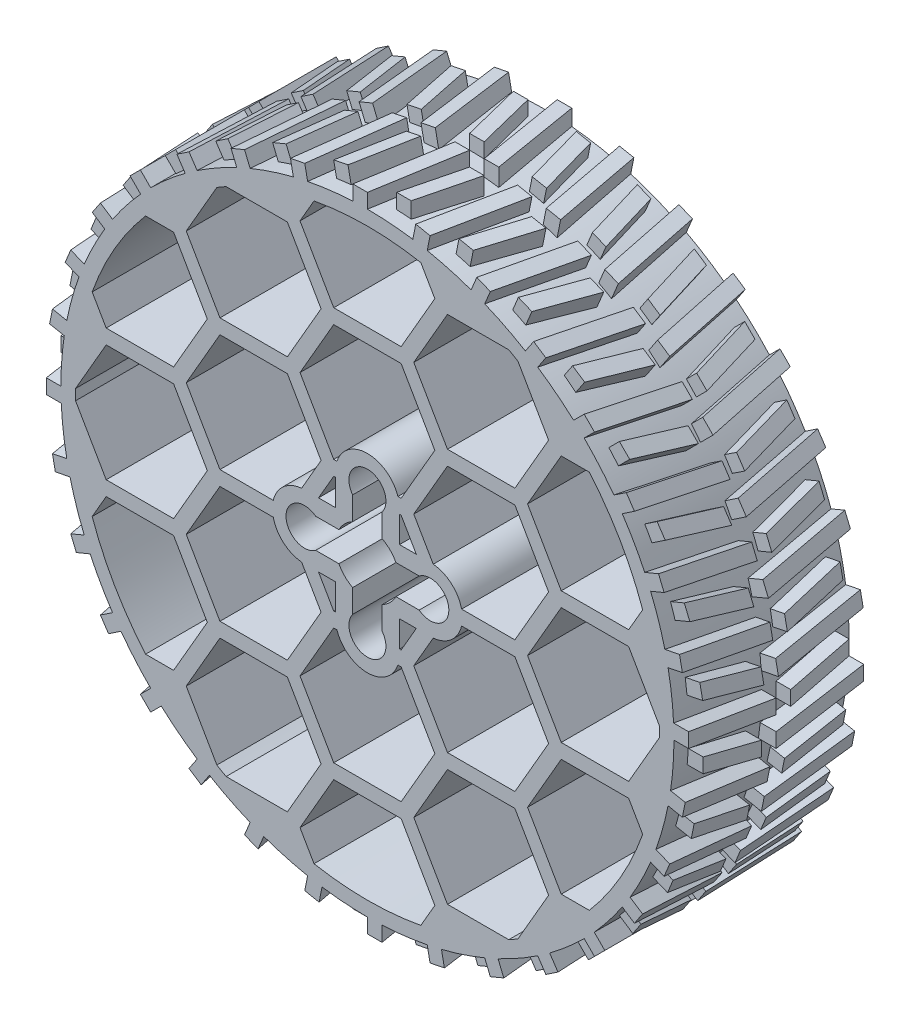
from build123d import *

# Parameters (mm, degrees)
SKETCH1_R           = 105
BOSS_EXTRUDE1_DEPTH = 60
SKETCH1_4_R         = 6.338999997
SKETCH1_4_R_2       = 3.175000013
SKETCH1_4_R_3       = 6.339
SKETCH1_4_R_4       = 3.175000003
SKETCH1_4_R_5       = 6.338999989
SKETCH1_4_R_6       = 3.175000016
BOSS_EXTRUDE2_DEPTH = 10
SKETCH1_6_R         = 6.339
SKETCH1_6_R_2       = 3.175000016
SKETCH1_6_R_3       = 6.338999989
SKETCH1_6_R_4       = 3.175000013
SKETCH1_6_R_5       = 3.175000003
SKETCH1_6_R_6       = 6.338999997
BOSS_EXTRUDE4_DEPTH = 30
BOSS_EXTRUDE5_START = -2
BOSS_EXTRUDE5_DEPTH = 7
CIRPATTERN1_COUNT   = 32


with BuildPart() as part:
    # Sketch1 → Boss-Extrude1 (new body)
    with BuildSketch(Plane.XY):
        Circle(SKETCH1_R)
        with BuildLine():
            Line((-11.547005384, 70), (-23.094010768, 90))
            Line((-23.094010768, 90), (-18.294940862, 98.312232905))
            ThreePointArc((-18.294940862, 98.312232905), (0, 100), (18.294940862, 98.312232905))
            Line((18.294940862, 98.312232905), (23.094010768, 90))
            Line((23.094010768, 90), (11.547005384, 70))
            Line((11.547005384, 70), (-11.547005384, 70))
        make_face(mode=Mode.SUBTRACT)
        with BuildLine():
            Line((-48.412291828, 87.5), (-27.424137787, 87.5))
            Line((-27.424137787, 87.5), (-15.877132403, 67.5))
            Line((-15.877132403, 67.5), (-27.424137787, 47.5))
            Line((-27.424137787, 47.5), (-50.518148554, 47.5))
            Line((-50.518148554, 47.5), (-62.065153938, 67.5))
            Line((-62.065153938, 67.5), (-51.571076917, 85.676274578))
            ThreePointArc((-51.571076917, 85.676274578), (-50, 86.602540378), (-48.412291828, 87.5))
        make_face(mode=Mode.SUBTRACT)
        with BuildLine():
            Line((27.424137787, 87.5), (48.412291828, 87.5))
            ThreePointArc((48.412291828, 87.5), (50, 86.602540378), (51.571076917, 85.676274578))
            Line((51.571076917, 85.676274578), (62.065153938, 67.5))
            Line((62.065153938, 67.5), (50.518148554, 47.5))
            Line((50.518148554, 47.5), (27.424137787, 47.5))
            Line((27.424137787, 47.5), (15.877132403, 67.5))
            Line((15.877132403, 67.5), (27.424137787, 87.5))
        make_face(mode=Mode.SUBTRACT)
        with BuildLine():
            Line((-75.993420768, 65), (-66.395280957, 65))
            Line((-66.395280957, 65), (-54.848275573, 45))
            Line((-54.848275573, 45), (-66.395280957, 25))
            Line((-66.395280957, 25), (-89.489291724, 25))
            Line((-89.489291724, 25), (-94.28836163, 33.312232905))
            ThreePointArc((-94.28836163, 33.312232905), (-86.602540378, 50), (-75.993420768, 65))
        make_face(mode=Mode.SUBTRACT)
        with BuildLine():
            Line((66.395280957, 65), (75.993420768, 65))
            ThreePointArc((75.993420768, 65), (86.602540378, 50), (94.28836163, 33.312232905))
            Line((94.28836163, 33.312232905), (89.489291724, 25))
            Line((89.489291724, 25), (66.395280957, 25))
            Line((66.395280957, 25), (54.848275573, 45))
            Line((54.848275573, 45), (66.395280957, 65))
        make_face(mode=Mode.SUBTRACT)
        with BuildLine():
            Line((-99.983368745, 1.823725422), (-89.489291724, 20))
            Line((-89.489291724, 20), (-66.395280957, 20))
            Line((-66.395280957, 20), (-54.848275573, 0))
            Line((-54.848275573, 0), (-66.395280957, -20))
            Line((-66.395280957, -20), (-89.489291724, -20))
            Line((-89.489291724, -20), (-99.983368745, -1.823725422))
            ThreePointArc((-99.983368745, -1.823725422), (-100, 0), (-99.983368745, 1.823725422))
        make_face(mode=Mode.SUBTRACT)
        with BuildLine():
            Line((89.489291724, 20), (99.983368745, 1.823725422))
            ThreePointArc((99.983368745, 1.823725422), (100, 0), (99.983368745, -1.823725422))
            Line((99.983368745, -1.823725422), (89.489291724, -20))
            Line((89.489291724, -20), (66.395280957, -20))
            Line((66.395280957, -20), (54.848275573, 0))
            Line((54.848275573, 0), (66.395280957, 20))
            Line((66.395280957, 20), (89.489291724, 20))
        make_face(mode=Mode.SUBTRACT)
        with BuildLine():
            Line((-94.28836163, -33.312232905), (-89.489291724, -25))
            Line((-89.489291724, -25), (-66.395280957, -25))
            Line((-66.395280957, -25), (-54.848275573, -45))
            Line((-54.848275573, -45), (-66.395280957, -65))
            Line((-66.395280957, -65), (-75.993420768, -65))
            ThreePointArc((-75.993420768, -65), (-86.602540378, -50), (-94.28836163, -33.312232905))
        make_face(mode=Mode.SUBTRACT)
        with BuildLine():
            Line((89.489291724, -25), (94.28836163, -33.312232905))
            ThreePointArc((94.28836163, -33.312232905), (86.602540378, -50), (75.993420768, -65))
            Line((75.993420768, -65), (66.395280957, -65))
            Line((66.395280957, -65), (54.848275573, -45))
            Line((54.848275573, -45), (66.395280957, -25))
            Line((66.395280957, -25), (89.489291724, -25))
        make_face(mode=Mode.SUBTRACT)
        with BuildLine():
            Line((-51.571076917, -85.676274578), (-62.065153938, -67.5))
            Line((-62.065153938, -67.5), (-50.518148554, -47.5))
            Line((-50.518148554, -47.5), (-27.424137787, -47.5))
            Line((-27.424137787, -47.5), (-15.877132403, -67.5))
            Line((-15.877132403, -67.5), (-27.424137787, -87.5))
            Line((-27.424137787, -87.5), (-48.412291828, -87.5))
            ThreePointArc((-48.412291828, -87.5), (-50, -86.602540378), (-51.571076917, -85.676274578))
        make_face(mode=Mode.SUBTRACT)
        with BuildLine():
            Line((62.065153938, -67.5), (51.571076917, -85.676274578))
            ThreePointArc((51.571076917, -85.676274578), (50, -86.602540378), (48.412291828, -87.5))
            Line((48.412291828, -87.5), (27.424137787, -87.5))
            Line((27.424137787, -87.5), (15.877132403, -67.5))
            Line((15.877132403, -67.5), (27.424137787, -47.5))
            Line((27.424137787, -47.5), (50.518148554, -47.5))
            Line((50.518148554, -47.5), (62.065153938, -67.5))
        make_face(mode=Mode.SUBTRACT)
        with BuildLine():
            Line((-18.294940862, -98.312232905), (-23.094010768, -90))
            Line((-23.094010768, -90), (-11.547005384, -70))
            Line((-11.547005384, -70), (11.547005384, -70))
            Line((11.547005384, -70), (23.094010768, -90))
            Line((23.094010768, -90), (18.294940862, -98.312232905))
            ThreePointArc((18.294940862, -98.312232905), (0, -100), (-18.294940862, -98.312232905))
        make_face(mode=Mode.SUBTRACT)
        with BuildLine():
            ThreePointArc((-32.260142561, -2.5), (-28.768380758, -8.298560137), (-22.542678431, -10.954935619))
            Line((-22.542678431, -10.954935619), (-15.877132403, -22.5))
            Line((-15.877132403, -22.5), (-27.424137787, -42.5))
            Line((-27.424137787, -42.5), (-50.518148554, -42.5))
            Line((-50.518148554, -42.5), (-62.065153938, -22.5))
            Line((-62.065153938, -22.5), (-50.518148554, -2.5))
            Line((-50.518148554, -2.5), (-32.260142561, -2.5))
        make_face(mode=Mode.SUBTRACT)
        Polygon((-16.743157813, -10.999999989), (-10.999999973, -10.999999989), (-10.999999973, -20), (-11.547005384, -20), align=None, mode=Mode.SUBTRACT)
        with BuildLine():
            ThreePointArc((-10.444314008, -25), (3.3e-08, -32.547999956), (10.444314074, -25))
            Line((10.444314074, -25), (11.547005384, -25))
            Line((11.547005384, -25), (23.094010768, -45))
            Line((23.094010768, -45), (11.547005384, -65))
            Line((11.547005384, -65), (-11.547005384, -65))
            Line((-11.547005384, -65), (-23.094010768, -45))
            Line((-23.094010768, -45), (-11.547005384, -25))
            Line((-11.547005384, -25), (-10.444314008, -25))
        make_face(mode=Mode.SUBTRACT)
        Polygon((11.00000004, -11.000000006), (16.743157803, -11.000000006), (11.547005384, -20), (11.00000004, -20), align=None, mode=Mode.SUBTRACT)
        with BuildLine():
            ThreePointArc((22.542678416, -10.954935645), (28.768380811, -8.298560182), (32.260142649, -2.5))
            Line((32.260142649, -2.5), (50.518148554, -2.5))
            Line((50.518148554, -2.5), (62.065153938, -22.5))
            Line((62.065153938, -22.5), (50.518148554, -42.5))
            Line((50.518148554, -42.5), (27.424137787, -42.5))
            Line((27.424137787, -42.5), (15.877132403, -22.5))
            Line((15.877132403, -22.5), (22.542678416, -10.954935645))
        make_face(mode=Mode.SUBTRACT)
        with BuildLine():
            ThreePointArc((-22.54267841, 10.954935656), (-28.768380763, 8.298560168), (-32.26014257, 2.5))
            Line((-32.26014257, 2.5), (-50.518148554, 2.5))
            Line((-50.518148554, 2.5), (-62.065153938, 22.5))
            Line((-62.065153938, 22.5), (-50.518148554, 42.5))
            Line((-50.518148554, 42.5), (-27.424137787, 42.5))
            Line((-27.424137787, 42.5), (-15.877132403, 22.5))
            Line((-15.877132403, 22.5), (-22.54267841, 10.954935656))
        make_face(mode=Mode.SUBTRACT)
        Polygon((-10.999999956, 20), (-10.999999956, 11.000000024), (-16.743157793, 11.000000024), (-11.547005384, 20), align=None, mode=Mode.SUBTRACT)
        with BuildLine():
            ThreePointArc((10.444314098, 25), (5.1e-08, 32.547999973), (-10.444313996, 25))
            Line((-10.444313996, 25), (-11.547005384, 25))
            Line((-11.547005384, 25), (-23.094010768, 45))
            Line((-23.094010768, 45), (-11.547005384, 65))
            Line((-11.547005384, 65), (11.547005384, 65))
            Line((11.547005384, 65), (23.094010768, 45))
            Line((23.094010768, 45), (11.547005384, 25))
            Line((11.547005384, 25), (10.444314098, 25))
        make_face(mode=Mode.SUBTRACT)
        with BuildLine():
            Line((9.767988869, 5.058299477), (17.727459807, 5.058299477))
            ThreePointArc((17.72745981, 5.058299474), (27.886999964, -4.5e-08), (17.727459795, -5.058299534))
            Line((17.727459789, -5.058299543), (9.767988835, -5.058299543))
            ThreePointArc((9.767988835, -5.058299543), (7.778174571, -7.778174624), (5.058299477, -9.767988869))
            Line((5.058299477, -9.767988869), (5.058299477, -17.727459807))
            ThreePointArc((5.058299479, -17.727459806), (-5e-08, -27.886999949), (-5.058299543, -17.727459788))
            Line((-5.058299543, -17.727459789), (-5.058299543, -9.767988835))
            ThreePointArc((-5.058299543, -9.767988835), (-7.778174624, -7.778174571), (-9.767988869, -5.058299477))
            Line((-9.767988869, -5.058299477), (-17.727459807, -5.058299477))
            ThreePointArc((-17.72745982, -5.05829946), (-27.886999941, 7.3e-08), (-17.727459789, 5.058299543))
            Line((-17.727459789, 5.058299543), (-9.767988835, 5.058299543))
            ThreePointArc((-9.767988835, 5.058299543), (-7.778174571, 7.778174624), (-5.058299477, 9.767988869))
            Line((-5.058299477, 9.767988869), (-5.058299477, 17.727459807))
            ThreePointArc((-5.058299461, 17.72745982), (6.9e-08, 27.886999964), (5.05829954, 17.727459791))
            Line((5.058299543, 17.727459789), (5.058299543, 9.767988835))
            ThreePointArc((5.058299543, 9.767988835), (7.778174624, 7.778174571), (9.767988869, 5.058299477))
        make_face(mode=Mode.SUBTRACT)
        Polygon((11.000000057, 11.000000006), (11.000000057, 20), (11.547005384, 20), (16.743157803, 11.000000006), align=None, mode=Mode.SUBTRACT)
        with BuildLine():
            ThreePointArc((32.260142649, 2.5), (28.768380811, 8.298560182), (22.542678416, 10.954935645))
            Line((22.542678416, 10.954935645), (15.877132403, 22.5))
            Line((15.877132403, 22.5), (27.424137787, 42.5))
            Line((27.424137787, 42.5), (50.518148554, 42.5))
            Line((50.518148554, 42.5), (62.065153938, 22.5))
            Line((62.065153938, 22.5), (50.518148554, 2.5))
            Line((50.518148554, 2.5), (32.260142649, 2.5))
        make_face(mode=Mode.SUBTRACT)
    extrude(amount=BOSS_EXTRUDE1_DEPTH)

    # Sketch1_4 → Boss-Extrude2 (add)
    with BuildSketch(Plane.XY):
        with Locations((5.1e-08, 21.547999967)):
            Circle(SKETCH1_4_R)
        with Locations((5.1e-08, 21.547999967)):
            Circle(SKETCH1_4_R_2, mode=Mode.SUBTRACT)
        with Locations((21.547999964, -3.6e-08)):
            Circle(SKETCH1_4_R_3)
        with Locations((21.547999974, -2.6e-08)):
            Circle(SKETCH1_4_R_4, mode=Mode.SUBTRACT)
        with Locations((-21.547999952, 5.4e-08)):
            Circle(SKETCH1_4_R_5)
        with Locations((-21.547999942, 4.4e-08)):
            Circle(SKETCH1_4_R_2, mode=Mode.SUBTRACT)
        with Locations((-3.9e-08, -21.547999949)):
            Circle(SKETCH1_4_R_3)
        with Locations((-1.9e-08, -21.547999949)):
            Circle(SKETCH1_4_R_6, mode=Mode.SUBTRACT)
    extrude(amount=BOSS_EXTRUDE2_DEPTH)

    # Sketch1_6 → Boss-Extrude4 (add)
    with BuildSketch(Plane.XY):
        with Locations((-3.9e-08, -21.547999949)):
            Circle(SKETCH1_6_R)
        with Locations((-1.9e-08, -21.547999949)):
            Circle(SKETCH1_6_R_2, mode=Mode.SUBTRACT)
        with Locations((-21.547999952, 5.4e-08)):
            Circle(SKETCH1_6_R_3)
        with Locations((-21.547999942, 4.4e-08)):
            Circle(SKETCH1_6_R_4, mode=Mode.SUBTRACT)
        with Locations((21.547999964, -3.6e-08)):
            Circle(SKETCH1_6_R)
        with Locations((21.547999974, -2.6e-08)):
            Circle(SKETCH1_6_R_5, mode=Mode.SUBTRACT)
        with Locations((5.1e-08, 21.547999967)):
            Circle(SKETCH1_6_R_6)
        with Locations((5.1e-08, 21.547999967)):
            Circle(SKETCH1_6_R_4, mode=Mode.SUBTRACT)
    extrude(amount=BOSS_EXTRUDE4_DEPTH)

    # Sketch2 → Boss-Extrude5 (add)
    with BuildSketch(Plane(origin=(105, 0, 0), x_dir=(0, 0, -1), z_dir=(1, 0, 0)).offset(BOSS_EXTRUDE5_START)):
        Polygon((-60, 5), (-60, 0), (-30, 0), align=None)
        Polygon((-30, 0), (-60, 0), (-30, -5), align=None)
        Polygon((-5, 5), (-25, 0), (-5, 0), align=None)
        Polygon((-5, 0), (-25, 0), (-25, -5), align=None)
        Polygon((-55, -5), (-35, -10), (-35, -15), (-55, -10), align=None)
        Polygon((-30, -15), (-30, -10), (0, -5), (0, -10), align=None)
    boss_extrude5 = extrude(amount=BOSS_EXTRUDE5_DEPTH)

    # CirPattern1: Boss-Extrude5 ×32 about axis
    cirpattern1_axis = Axis((0, 0, 0), (0, 0, 1))
    for i in range(1, CIRPATTERN1_COUNT):
        add(boss_extrude5.rotate(cirpattern1_axis, i * 360 / CIRPATTERN1_COUNT))


solid = part.part
